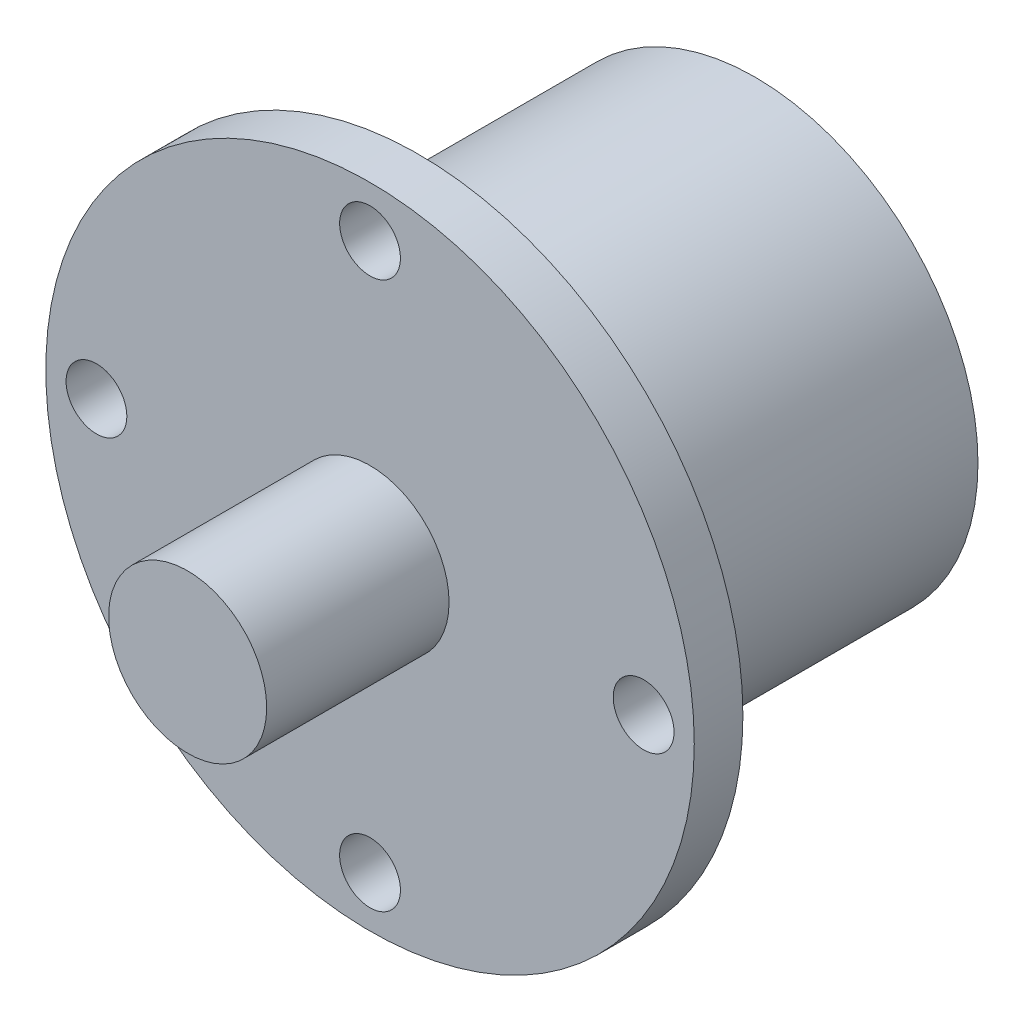
from build123d import *

# Parameters (mm, degrees)
SKETCH_1_R      = 16
SKETCH_1_R_2    = 1.5
EXTRUDE_1_DEPTH = 2.4
SKETCH_2_R      = 3.9
EXTRUDE_2_DEPTH = 9
SKETCH_3_R      = 11
EXTRUDE_3_DEPTH = 16.6


with BuildPart() as part:
    # Эскиз1 → Бобышка-Вытянуть1 (new body)
    with BuildSketch(Plane.XY):
        Circle(SKETCH_1_R)
        with Locations((-13.5, 0)):
            Circle(SKETCH_1_R_2, mode=Mode.SUBTRACT)
        with Locations((0, 13.5)):
            Circle(SKETCH_1_R_2, mode=Mode.SUBTRACT)
        with Locations((13.5, 0)):
            Circle(SKETCH_1_R_2, mode=Mode.SUBTRACT)
        with Locations((0, -13.5)):
            Circle(SKETCH_1_R_2, mode=Mode.SUBTRACT)
    extrude(amount=EXTRUDE_1_DEPTH)

    # Эскиз2 → Бобышка-Вытянуть2 (add)
    with BuildSketch(Plane.XY.offset(2.4)):
        Circle(SKETCH_2_R)
    extrude(amount=EXTRUDE_2_DEPTH)

    # Эскиз3 → Бобышка-Вытянуть3 (add)
    with BuildSketch(Plane(origin=(0, 0, 0), x_dir=(-1, 0, 0), z_dir=(0, 0, -1))):
        Circle(SKETCH_3_R)
    extrude(amount=EXTRUDE_3_DEPTH)


solid = part.part
